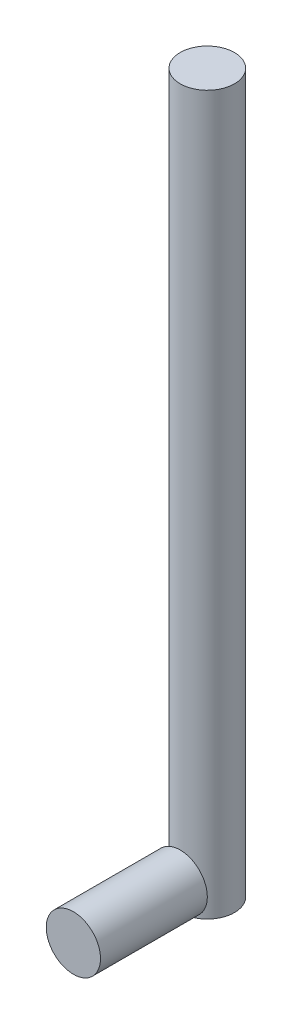
from build123d import *

# Parameters (mm, degrees)
SKETCH1_R           = 6.5
BOSS_EXTRUDE1_DEPTH = 172
SKETCH2_R           = 6.5
BOSS_EXTRUDE2_DEPTH = 25.6


with BuildPart() as part:
    # Sketch1 → Boss-Extrude1 (new body)
    with BuildSketch(Plane(origin=(0, 0, 0), x_dir=(1, 0, 0), z_dir=(0, 1, 0))):
        Circle(SKETCH1_R)
    extrude(amount=BOSS_EXTRUDE1_DEPTH)


with BuildPart() as body_2:
    # Sketch2 → Boss-Extrude2 (new body)
    with BuildSketch(Plane.XY.offset(6.5)):
        with Locations((0, 6.5)):
            Circle(SKETCH2_R)
    extrude(amount=BOSS_EXTRUDE2_DEPTH)


solid = Compound([part.part, body_2.part])
